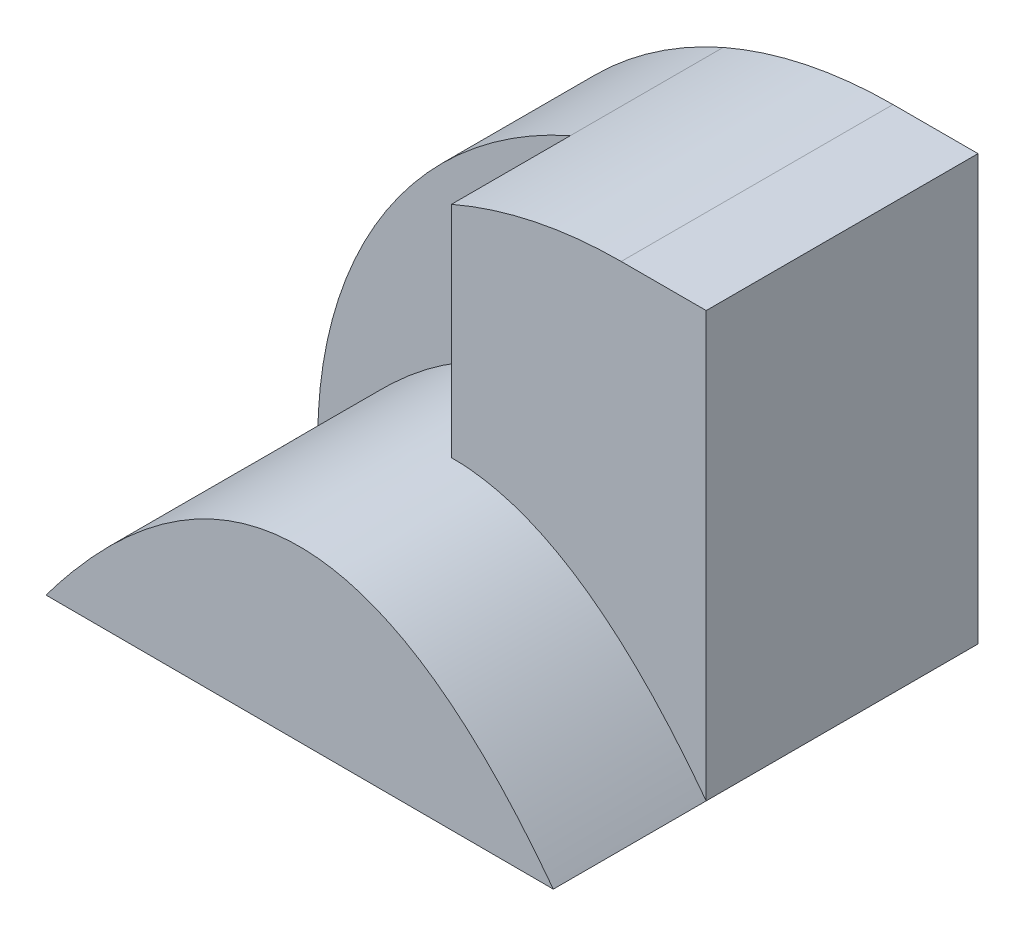
from build123d import *

# Parameters (mm, degrees)
BOSS_EXTRUDE1_DEPTH = 3.2
BOSS_EXTRUDE2_DEPTH = 1.8
BOSS_EXTRUDE3_DEPTH = 3.2


with BuildPart() as part:
    # Sketch1 → Boss-Extrude1 (new body)
    with BuildSketch(Plane.XY):
        with BuildLine():
            Line((-3, 4.582902076), (-3, 0))
            Line((-3, 0), (0, 0))
            Line((0, 0), (0, 5))
            Line((0, 5), (-1.00094518, 5))
            ThreePointArc((-1.00094518, 5), (-2.021997437, 4.894614703), (-3, 4.582902076))
        make_face()
    extrude(amount=BOSS_EXTRUDE1_DEPTH)

    # Sketch2 → Boss-Extrude2 (add)
    with BuildSketch(Plane(origin=(0, 0, 0), x_dir=(-1, 0, 0), z_dir=(0, 0, -1))):
        with BuildLine():
            Line((3, 0), (5.973192614, 0))
            ThreePointArc((5.973192614, 0), (5.167805035, 2.733390386), (3, 4.582902076))
            Line((3, 4.582902076), (3, 0))
        make_face()
    extrude(amount=-BOSS_EXTRUDE2_DEPTH)

    # Sketch3 → Boss-Extrude3 (add)
    with BuildSketch(Plane.XY.offset(1.8)):
        with BuildLine():
            Line((0, 0), (-5.973207287, 0.012113161))
            add(Edge.make_bspline(
                [(-5.973207287, 0.012113161), (-2.989270297, 3.993959552), (0, 0)],
                knots=[0, 0, 0, 1, 1, 1], degree=2))
        make_face()
    extrude(amount=BOSS_EXTRUDE3_DEPTH)


solid = part.part
